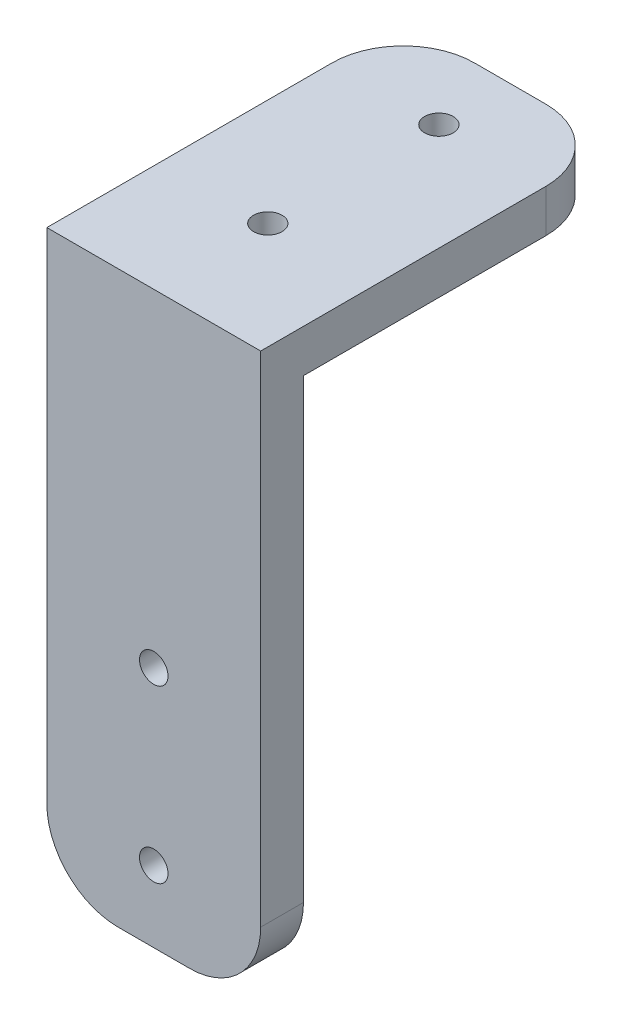
from build123d import *

# Parameters (mm, degrees)
SKETCH_1_R      = 1
EXTRUDE_1_DEPTH = 3
SKETCH_2_R      = 1
EXTRUDE_2_DEPTH = 3


with BuildPart() as part:
    # 草图1 → 凸台-拉伸1 (new body)
    with BuildSketch(Plane.XY):
        with BuildLine():
            Line((5, 0), (10, 0))
            ThreePointArc((10, 0), (13.535533906, 1.464466094), (15, 5))
            Line((15, 5), (15, 40))
            Line((15, 40), (0, 40))
            Line((0, 40), (0, 5))
            ThreePointArc((0, 5), (1.464466094, 1.464466094), (5, 0))
        make_face()
        with Locations((7.5, 5)):
            Circle(SKETCH_1_R, mode=Mode.SUBTRACT)
        with Locations((7.5, 17)):
            Circle(SKETCH_1_R, mode=Mode.SUBTRACT)
    extrude(amount=EXTRUDE_1_DEPTH)

    # 草图2 → 凸台-拉伸2 (add)
    with BuildSketch(Plane(origin=(0, 40, 0), x_dir=(-1, 0, 0), z_dir=(0, -1, 0))):
        with BuildLine():
            Line((-15, -3), (0, -3))
            Line((0, -3), (0, 17))
            ThreePointArc((0, 17), (-1.464466094, 20.535533906), (-5, 22))
            Line((-5, 22), (-10, 22))
            ThreePointArc((-10, 22), (-13.535533906, 20.535533906), (-15, 17))
            Line((-15, 17), (-15, -3))
        make_face()
        with Locations((-7.5, 17)):
            Circle(SKETCH_2_R, mode=Mode.SUBTRACT)
        with Locations((-7.5, 5)):
            Circle(SKETCH_2_R, mode=Mode.SUBTRACT)
    extrude(amount=EXTRUDE_2_DEPTH)


solid = part.part
